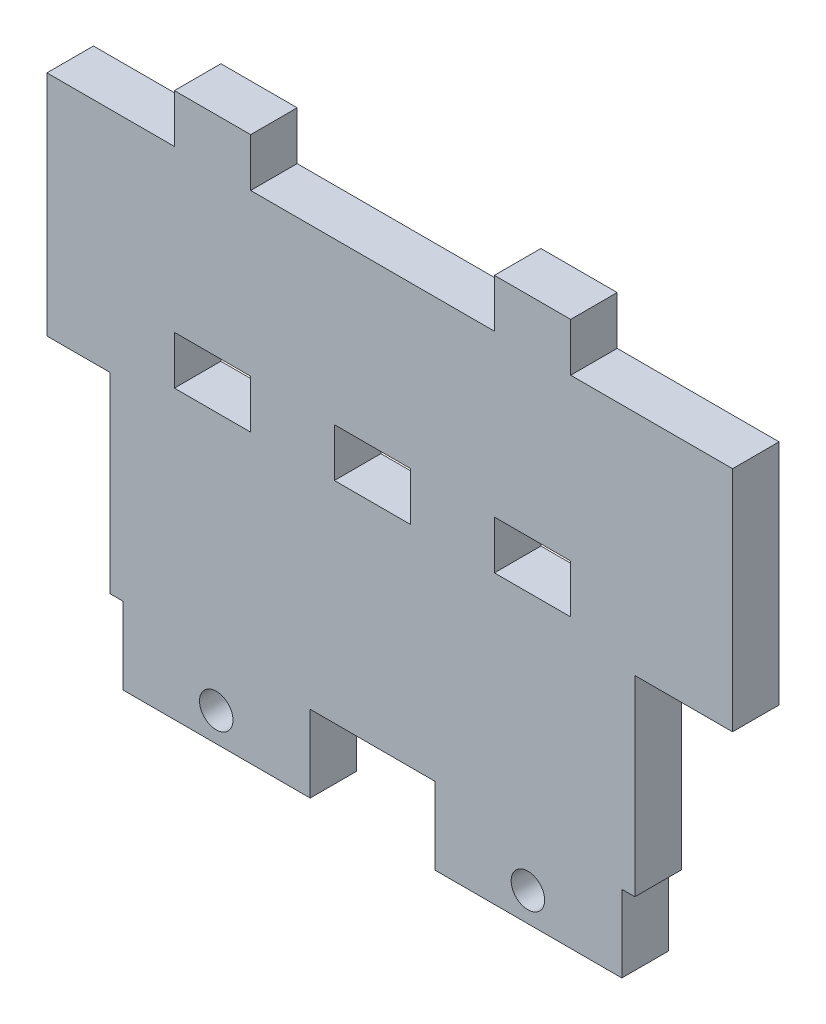
from build123d import *

# Parameters (mm, degrees)
BOSS_EXTRUDE1_DEPTH = 5
CUT_EXTRUDE1_REACH  = 7
SKETCH2_R           = 1.8
SKETCH2_W           = 8.2
SKETCH2_H           = 5.2
SKETCH3_W           = 3.7
SKETCH3_H           = 24.5
BOSS_EXTRUDE4_DEPTH = 5
SKETCH4_W           = 8.2
SKETCH4_H           = 5.2
BOSS_EXTRUDE7_DEPTH = 5


with BuildPart() as part:
    # Sketch1 → Boss-Extrude1 (new body)
    with BuildSketch(Plane.XY):
        Polygon((26.917617282, -2.091463415), (33.717617282, -2.091463415), (33.717617282, 22.408536585), (-36.282382718, 22.408536585), (-36.282382718, -2.091463415), (-29.482382718, -2.091463415), (-29.482382718, -22.691463415), (-28.082382718, -22.691463415), (-28.082382718, -30.955691057), (-7.982382718, -30.955691057), (-7.982382718, -22.691463415), (5.417617282, -22.691463415), (5.417617282, -30.955691057), (25.517617282, -30.955691057), (25.517617282, -22.691463415), (26.917617282, -22.691463415), align=None)
    extrude(amount=BOSS_EXTRUDE1_DEPTH)

    # Sketch2 → Cut-Extrude1 (cut, up to next)
    with BuildSketch(Plane.XY.offset(5), mode=Mode.PRIVATE) as cut_extrude1_sk1:
        with Locations((15.417617282, -27.855691057)):
            Circle(SKETCH2_R)
    cut_extrude1_tool1 = extrude(cut_extrude1_sk1.sketch, amount=-CUT_EXTRUDE1_REACH, mode=Mode.PRIVATE) & part.part
    add(cut_extrude1_tool1.solids().sort_by_distance((15.417617, -27.855691, 5))[0], mode=Mode.SUBTRACT)
    # Sketch2 → Cut-Extrude1 (cut, up to next)
    with BuildSketch(Plane.XY.offset(5), mode=Mode.PRIVATE) as cut_extrude1_sk2:
        with Locations((-18.082382718, -27.855691057)):
            Circle(SKETCH2_R)
    cut_extrude1_tool2 = extrude(cut_extrude1_sk2.sketch, amount=-CUT_EXTRUDE1_REACH, mode=Mode.PRIVATE) & part.part
    add(cut_extrude1_tool2.solids().sort_by_distance((-18.082383, -27.855691, 5))[0], mode=Mode.SUBTRACT)
    # Sketch2 → Cut-Extrude1 (cut, up to next)
    with BuildSketch(Plane.XY.offset(5), mode=Mode.PRIVATE) as cut_extrude1_sk3:
        with Locations((-18.482382718, 2.508536585)):
            Rectangle(SKETCH2_W, SKETCH2_H)
    cut_extrude1_tool3 = extrude(cut_extrude1_sk3.sketch, amount=-CUT_EXTRUDE1_REACH, mode=Mode.PRIVATE) & part.part
    add(cut_extrude1_tool3.solids().sort_by_distance((-18.482383, 2.508537, 5))[0], mode=Mode.SUBTRACT)
    # Sketch2 → Cut-Extrude1 (cut, up to next)
    with BuildSketch(Plane.XY.offset(5), mode=Mode.PRIVATE) as cut_extrude1_sk4:
        with Locations((-1.282382718, 2.508536585)):
            Rectangle(SKETCH2_W, SKETCH2_H)
    cut_extrude1_tool4 = extrude(cut_extrude1_sk4.sketch, amount=-CUT_EXTRUDE1_REACH, mode=Mode.PRIVATE) & part.part
    add(cut_extrude1_tool4.solids().sort_by_distance((-1.282383, 2.508537, 5))[0], mode=Mode.SUBTRACT)
    # Sketch2 → Cut-Extrude1 (cut, up to next)
    with BuildSketch(Plane.XY.offset(5), mode=Mode.PRIVATE) as cut_extrude1_sk5:
        with Locations((15.917617282, 2.508536585)):
            Rectangle(SKETCH2_W, SKETCH2_H)
    cut_extrude1_tool5 = extrude(cut_extrude1_sk5.sketch, amount=-CUT_EXTRUDE1_REACH, mode=Mode.PRIVATE) & part.part
    add(cut_extrude1_tool5.solids().sort_by_distance((15.917617, 2.508537, 5))[0], mode=Mode.SUBTRACT)

    # Sketch3 → Boss-Extrude4 (add)
    with BuildSketch(Plane.XY.offset(5)):
        with Locations((35.567617282, 10.158536585)):
            Rectangle(SKETCH3_W, SKETCH3_H)
    extrude(amount=-BOSS_EXTRUDE4_DEPTH)

    # Sketch4 → Boss-Extrude7 (add)
    with BuildSketch(Plane.XY.offset(5)):
        with Locations((-18.482382718, 25.008536585)):
            Rectangle(SKETCH4_W, SKETCH4_H)
        with Locations((15.917617282, 25.008536585)):
            Rectangle(SKETCH4_W, SKETCH4_H)
    extrude(amount=-BOSS_EXTRUDE7_DEPTH)


solid = part.part
